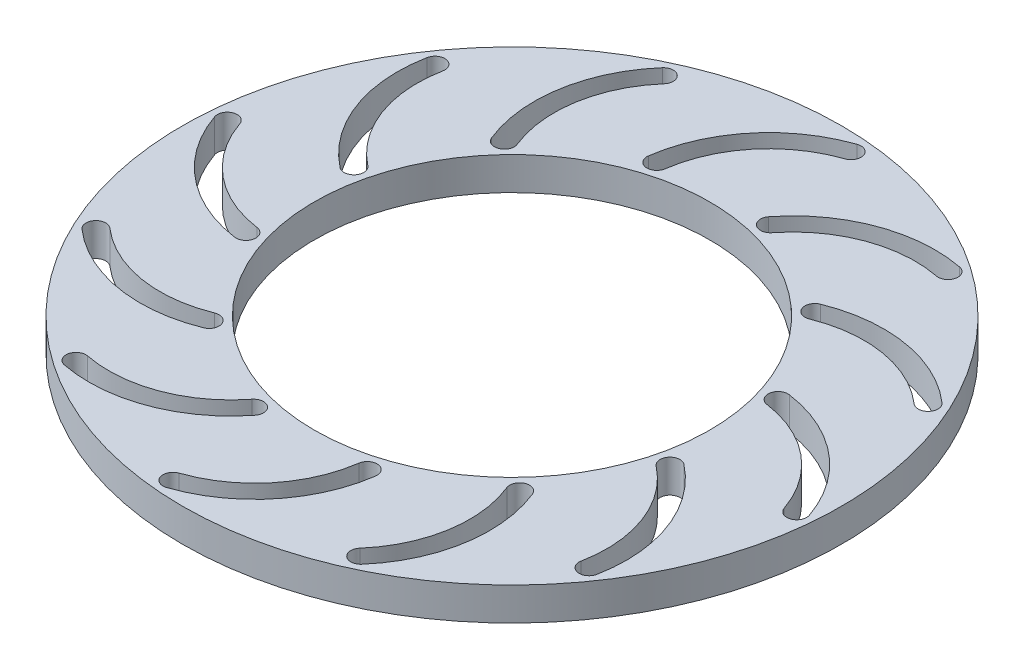
from build123d import *

# Parameters (mm, degrees)
SKETCH1_R           = 5
SKETCH1_R_2         = 3
BOSS_EXTRUDE1_DEPTH = 0.5
CUT_EXTRUDE2_DEPTH  = 0.5
CUT_EXTRUDE3_DEPTH  = 0.5
CUT_EXTRUDE5_DEPTH  = 0.5


with BuildPart() as part:
    # Sketch1 → Boss-Extrude1 (new body)
    with BuildSketch(Plane(origin=(0, 0, 0), x_dir=(1, 0, 0), z_dir=(0, 1, 0))):
        Circle(SKETCH1_R)
        Circle(SKETCH1_R_2, mode=Mode.SUBTRACT)
    extrude(amount=BOSS_EXTRUDE1_DEPTH)

    # Sketch1_4 → Cut-Extrude2 (cut)
    with BuildSketch(Plane(origin=(0, 0, 0), x_dir=(1, 0, 0), z_dir=(0, 1, 0))):
        with BuildLine():
            ThreePointArc((-3.744681424, 2.694339182), (-3.662355303, 1.691396556), (-3.06721905, 0.879926074))
            ThreePointArc((-3.06721905, 0.879926074), (-3.041225351, 0.669392639), (-3.251758787, 0.64339894))
            ThreePointArc((-3.251758787, 0.64339894), (-3.943403621, 1.586459229), (-4.039079925, 2.7520412))
            ThreePointArc((-4.039079925, 2.7520412), (-3.863029666, 2.870389441), (-3.744681424, 2.694339182))
        make_face()
    extrude(amount=CUT_EXTRUDE2_DEPTH, mode=Mode.SUBTRACT)

    # Sketch1_6 → Cut-Extrude3 (cut)
    with BuildSketch(Plane(origin=(0, 0, 0), x_dir=(1, 0, 0), z_dir=(0, 1, 0))):
        with BuildLine():
            ThreePointArc((2.7520412, 4.039079925), (1.586459229, 3.943403621), (0.64339894, 3.251758787))
            ThreePointArc((0.64339894, 3.251758787), (0.669392639, 3.041225351), (0.879926074, 3.06721905))
            ThreePointArc((0.879926074, 3.06721905), (1.691396556, 3.662355303), (2.694339182, 3.744681424))
            ThreePointArc((2.694339182, 3.744681424), (2.870389441, 3.863029666), (2.7520412, 4.039079925))
        make_face()
        with BuildLine():
            ThreePointArc((-1.895819652, 4.20570689), (-2.325994452, 3.295970036), (-2.216326579, 2.295647859))
            ThreePointArc((-2.216326579, 2.295647859), (-2.299082093, 2.100323706), (-2.494406247, 2.18307922))
            ThreePointArc((-2.494406247, 2.18307922), (-2.621858099, 3.345615805), (-2.121925223, 4.402877554))
            ThreePointArc((-2.121925223, 4.402877554), (-1.910287106, 4.417345007), (-1.895819652, 4.20570689))
        make_face()
        with BuildLine():
            ThreePointArc((0.461025466, 4.590158833), (-0.366385266, 4.017391008), (-0.771571191, 3.096252653))
            ThreePointArc((-0.771571191, 3.096252653), (-0.940901645, 2.968474732), (-1.068679567, 3.137805186))
            ThreePointArc((-1.068679567, 3.137805186), (-0.597787817, 4.208317328), (0.363797629, 4.873966423))
            ThreePointArc((0.363797629, 4.873966423), (0.554315342, 4.780676547), (0.461025466, 4.590158833))
        make_face()
    extrude(amount=CUT_EXTRUDE3_DEPTH, mode=Mode.SUBTRACT)

    # Sketch1_7 → Cut-Extrude5 (cut)
    with BuildSketch(Plane(origin=(0, 0, 0), x_dir=(1, 0, 0), z_dir=(0, 1, 0))):
        with BuildLine():
            ThreePointArc((4.20570689, 1.895819652), (3.295970036, 2.325994452), (2.295647859, 2.216326579))
            ThreePointArc((2.295647859, 2.216326579), (2.100323706, 2.299082093), (2.18307922, 2.494406247))
            ThreePointArc((2.18307922, 2.494406247), (3.345615805, 2.621858099), (4.402877554, 2.121925223))
            ThreePointArc((4.402877554, 2.121925223), (4.417345007, 1.910287106), (4.20570689, 1.895819652))
        make_face()
        with BuildLine():
            ThreePointArc((4.590158833, -0.461025466), (4.017391008, 0.366385266), (3.096252653, 0.771571191))
            ThreePointArc((3.096252653, 0.771571191), (2.968474732, 0.940901645), (3.137805186, 1.068679567))
            ThreePointArc((3.137805186, 1.068679567), (4.208317328, 0.597787817), (4.873966423, -0.363797629))
            ThreePointArc((4.873966423, -0.363797629), (4.780676547, -0.554315342), (4.590158833, -0.461025466))
        make_face()
        with BuildLine():
            ThreePointArc((3.744681424, -2.694339182), (3.662355303, -1.691396556), (3.06721905, -0.879926074))
            ThreePointArc((3.06721905, -0.879926074), (3.041225351, -0.669392639), (3.251758787, -0.64339894))
            ThreePointArc((3.251758787, -0.64339894), (3.943403621, -1.586459229), (4.039079925, -2.7520412))
            ThreePointArc((4.039079925, -2.7520412), (3.863029666, -2.870389441), (3.744681424, -2.694339182))
        make_face()
        with BuildLine():
            ThreePointArc((1.895819652, -4.20570689), (2.325994452, -3.295970036), (2.216326579, -2.295647859))
            ThreePointArc((2.216326579, -2.295647859), (2.299082093, -2.100323706), (2.494406247, -2.18307922))
            ThreePointArc((2.494406247, -2.18307922), (2.621858099, -3.345615805), (2.121925223, -4.402877554))
            ThreePointArc((2.121925223, -4.402877554), (1.910287106, -4.417345007), (1.895819652, -4.20570689))
        make_face()
        with BuildLine():
            ThreePointArc((-0.461025466, -4.590158833), (0.366385266, -4.017391008), (0.771571191, -3.096252653))
            ThreePointArc((0.771571191, -3.096252653), (0.940901645, -2.968474732), (1.068679567, -3.137805186))
            ThreePointArc((1.068679567, -3.137805186), (0.597787817, -4.208317328), (-0.363797629, -4.873966423))
            ThreePointArc((-0.363797629, -4.873966423), (-0.554315342, -4.780676547), (-0.461025466, -4.590158833))
        make_face()
        with BuildLine():
            ThreePointArc((-2.694339182, -3.744681424), (-1.691396556, -3.662355303), (-0.879926074, -3.06721905))
            ThreePointArc((-0.879926074, -3.06721905), (-0.669392639, -3.041225351), (-0.64339894, -3.251758787))
            ThreePointArc((-0.64339894, -3.251758787), (-1.586459229, -3.943403621), (-2.7520412, -4.039079925))
            ThreePointArc((-2.7520412, -4.039079925), (-2.870389441, -3.863029666), (-2.694339182, -3.744681424))
        make_face()
        with BuildLine():
            ThreePointArc((-4.20570689, -1.895819652), (-3.295970036, -2.325994452), (-2.295647859, -2.216326579))
            ThreePointArc((-2.295647859, -2.216326579), (-2.100323706, -2.299082093), (-2.18307922, -2.494406247))
            ThreePointArc((-2.18307922, -2.494406247), (-3.345615805, -2.621858099), (-4.402877554, -2.121925223))
            ThreePointArc((-4.402877554, -2.121925223), (-4.417345007, -1.910287106), (-4.20570689, -1.895819652))
        make_face()
        with BuildLine():
            ThreePointArc((-4.590158833, 0.461025466), (-4.017391008, -0.366385266), (-3.096252653, -0.771571191))
            ThreePointArc((-3.096252653, -0.771571191), (-2.968474732, -0.940901645), (-3.137805186, -1.068679567))
            ThreePointArc((-3.137805186, -1.068679567), (-4.208317328, -0.597787817), (-4.873966423, 0.363797629))
            ThreePointArc((-4.873966423, 0.363797629), (-4.780676547, 0.554315342), (-4.590158833, 0.461025466))
        make_face()
    extrude(amount=CUT_EXTRUDE5_DEPTH, mode=Mode.SUBTRACT)


solid = part.part
